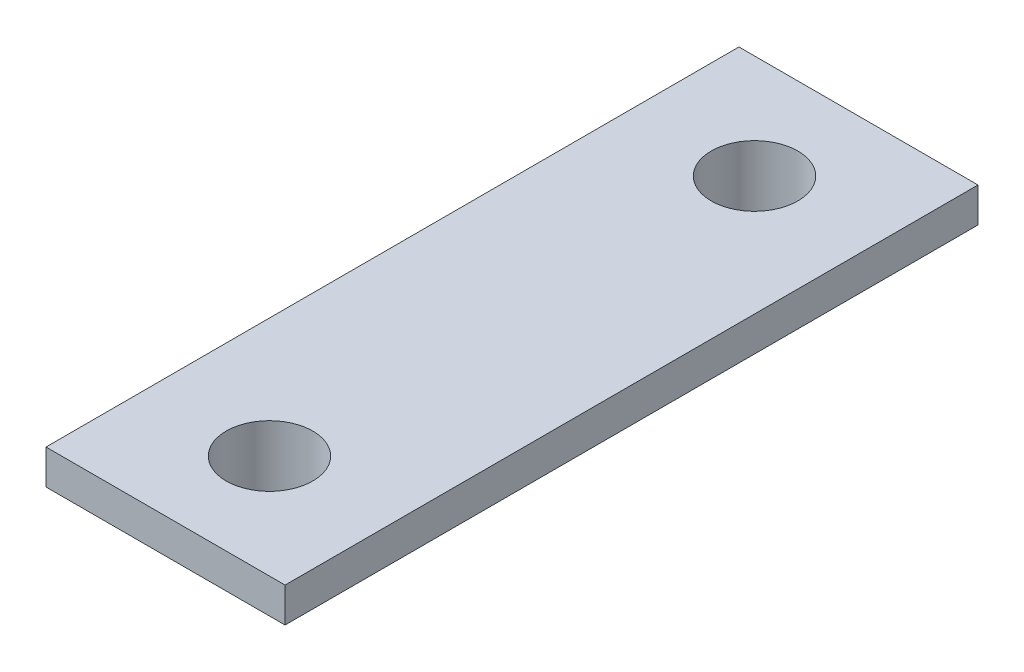
from build123d import *

# Parameters (mm, degrees)
SKETCH1_W             = 6.9
SKETCH1_H             = 20
BOSS_EXTRUDE1_DEPTH   = 1
SKETCH4_R             = 1.9
BOSS_EXTRUDE2_DEPTH   = 0.8
M3X0_5_TAPPED_HOLE1_D = 2.5


with BuildPart() as part:
    # Sketch1 → Boss-Extrude1 (new body)
    with BuildSketch(Plane(origin=(0, 0, 0), x_dir=(1, 0, 0), z_dir=(0, 1, 0))):
        Rectangle(SKETCH1_W, SKETCH1_H)
    extrude(amount=BOSS_EXTRUDE1_DEPTH)

    # Sketch4 → Boss-Extrude2 (add)
    with BuildSketch(Plane.XZ):
        with Locations((0, -7)):
            Circle(SKETCH4_R)
    boss_extrude2 = extrude(amount=BOSS_EXTRUDE2_DEPTH)

    # Mirror2: Boss-Extrude2 across plane
    add(boss_extrude2.mirror(Plane.XY))

    # M3x0.5 Tapped Hole1 (through all)
    with Locations(Plane(origin=(0, 1, 0), x_dir=(1, 0, 0), z_dir=(0, 1, 0))):
        with Locations((0, 7)):
            m3x0_5_tapped_hole1 = Hole(M3X0_5_TAPPED_HOLE1_D / 2)

    # Mirror1: M3x0.5 Tapped Hole1 across plane
    add(m3x0_5_tapped_hole1.mirror(Plane.XY), mode=Mode.SUBTRACT)


solid = part.part
